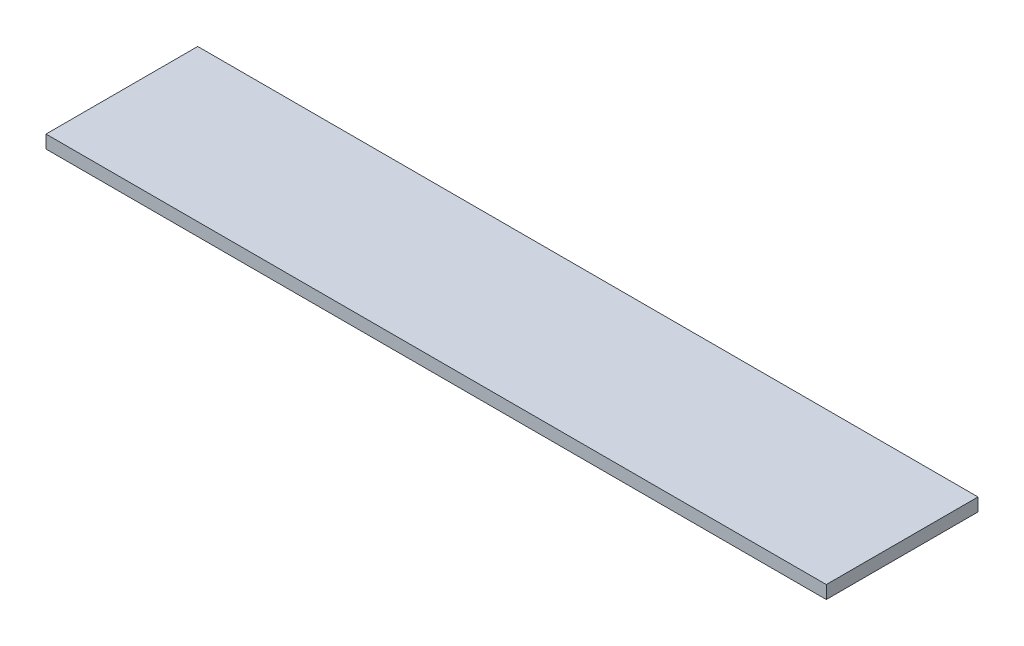
from build123d import *

# Parameters (mm, degrees)
SKETCH1_W           = 180
SKETCH1_H           = 35
BOSS_EXTRUDE1_DEPTH = 3


with BuildPart() as part:
    # Sketch1 → Boss-Extrude1 (new body)
    with BuildSketch(Plane(origin=(0, 0, 0), x_dir=(1, 0, 0), z_dir=(0, 1, 0))):
        with Locations((-14.686936777, 41.10573468)):
            Rectangle(SKETCH1_W, SKETCH1_H)
    extrude(amount=BOSS_EXTRUDE1_DEPTH)


solid = part.part
